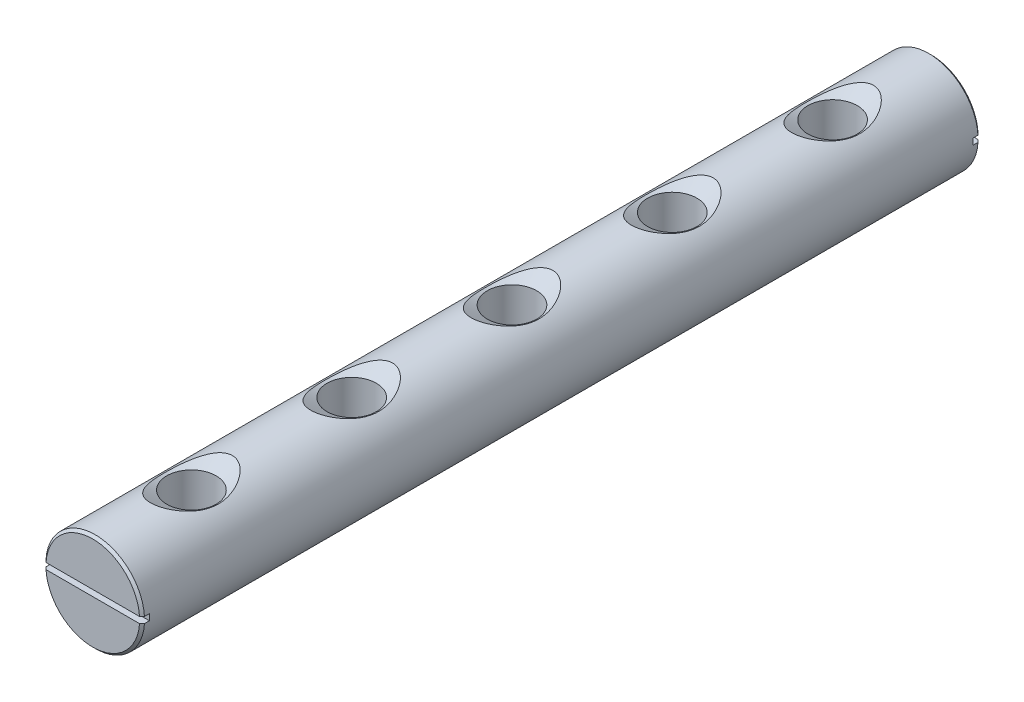
from build123d import *

# Parameters (mm, degrees)
SKETCH1_W          = 215.9
SKETCH1_H          = 12.7
CHAMFER1_SIZE      = 0.635
SKETCH9_W          = 25.4
SKETCH9_H          = 1.5875
CUT_EXTRUDE2_DEPTH = 1.905
LPATTERN3_COUNT    = 3
LPATTERN3_PITCH    = 41.275
LPATTERN4_COUNT    = 3
LPATTERN4_PITCH    = 41.275


with BuildPart() as part:
    # Sketch1 → Base-Revolve (revolve)
    with BuildSketch(Plane(origin=(0, 0, 0), x_dir=(0, 0, -1), z_dir=(1, 0, 0)), mode=Mode.PRIVATE) as base_revolve_sk:
        with Locations((0, 6.35)):
            Rectangle(SKETCH1_W, SKETCH1_H)
    revolve(base_revolve_sk.sketch.rotate(Axis((0, 0, 107.95), (0, 0, -1)), 90), axis=Axis((0, 0, 107.95), (0, 0, -1)))  # turned: the seam where the file's is

    # Chamfer1
    chamfer1_edges = [part.edges().sort_by_distance(p)[0] for p in [
        (-12.7, 0, -107.95),
        (-12.7, 0, 107.95),
    ]]
    chamfer(chamfer1_edges, length=CHAMFER1_SIZE)

    # Sketch9 → Cut-Extrude2 (cut)
    with BuildSketch(Plane.XY.offset(107.95)):
        Rectangle(SKETCH9_W, SKETCH9_H)
    cut_extrude2 = extrude(amount=-CUT_EXTRUDE2_DEPTH, mode=Mode.SUBTRACT)

    # Mirror1: Cut-Extrude2 across plane
    add(cut_extrude2.mirror(Plane.XY), mode=Mode.SUBTRACT)

    # Sketch17 → 1_2-13 Tapped Hole1 (revolve, cut)
    with BuildSketch(Plane(origin=(0, 12.7, 0), x_dir=(0, 0, 1), z_dir=(1, 0, 0))):
        Polygon((0, 0), (0, 25.4), (10.541, 25.4), (6.35, 22.980325022), (6.35, 2.419674978), (10.541, 0), align=None)
    f_1_2_13_tapped_hole1 = revolve(axis=Axis((0, 19.05, 0), (0, -1, 0)), mode=Mode.SUBTRACT)

    # LPattern3: 1_2-13 Tapped Hole1 ×3
    with Locations(*[(0, 0, -i * LPATTERN3_PITCH) for i in range(1, LPATTERN3_COUNT)]):
        add(f_1_2_13_tapped_hole1, mode=Mode.SUBTRACT)

    # LPattern4: 1_2-13 Tapped Hole1 ×3
    with Locations(*[(0, 0, i * LPATTERN4_PITCH) for i in range(1, LPATTERN4_COUNT)]):
        add(f_1_2_13_tapped_hole1, mode=Mode.SUBTRACT)


solid = part.part
